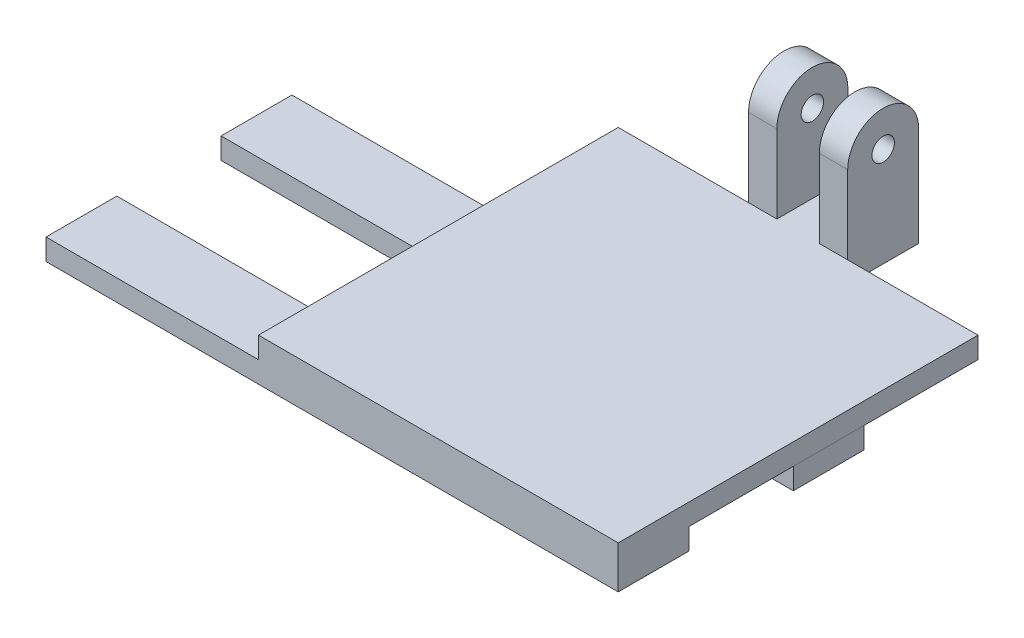
from build123d import *

# Parameters (mm, degrees)
BOSS_EXTRUDE1_DEPTH = 3
SKETCH1_3_W         = 4
SKETCH1_3_H         = 10.023203152
BOSS_EXTRUDE2_DEPTH = 19.05
SKETCH2_R           = 1.5875
CUT_EXTRUDE1_DEPTH  = 19.05
SKETCH3_W           = 80.796379589
SKETCH3_H           = 10
BOSS_EXTRUDE3_DEPTH = 3


with BuildPart() as part:
    # Sketch1 → Boss-Extrude1 (new body)
    with BuildSketch(Plane(origin=(0, 0, 0), x_dir=(1, 0, 0), z_dir=(0, 1, 0))):
        Polygon((0, 50.8), (0, 0), (50.8, 0), (50.8, 50.8), (28.4, 50.8), (28.4, 60.823203152), (22.4, 60.823203152), (22.4, 50.8), align=None)
    extrude(amount=BOSS_EXTRUDE1_DEPTH)

    # Sketch1_3 → Boss-Extrude2 (add)
    with BuildSketch(Plane(origin=(0, 0, 0), x_dir=(1, 0, 0), z_dir=(0, 1, 0))):
        with Locations((20.4, 55.811601576)):
            Rectangle(SKETCH1_3_W, SKETCH1_3_H)
        with Locations((30.4, 55.811601576)):
            Rectangle(SKETCH1_3_W, SKETCH1_3_H)
    extrude(amount=BOSS_EXTRUDE2_DEPTH)

    # Sketch2 → Cut-Extrude1 (cut)
    with BuildSketch(Plane(origin=(32.4, 0, 0), x_dir=(0, 0, -1), z_dir=(1, 0, 0))):
        with Locations((55.811601576, 14.038398424)):
            Circle(SKETCH2_R)
        with BuildLine():
            Line((50.8, 14.038398424), (49.911458456, 20.395059664))
            Line((49.911458456, 20.395059664), (64.501767063, 21.247740037))
            Line((64.501767063, 21.247740037), (60.823203152, 14.038398424))
            ThreePointArc((60.823203152, 14.038398424), (55.811601576, 19.05), (50.8, 14.038398424))
        make_face()
    extrude(amount=-CUT_EXTRUDE1_DEPTH, mode=Mode.SUBTRACT)

    # Sketch3 → Boss-Extrude3 (add)
    with BuildSketch(Plane.XZ):
        Polygon((0, 0), (-30, 0), (-30, -10), (50.8, -10), (50.8, 0), align=None)
        with Locations((10.398189795, -29.723216131)):
            Rectangle(SKETCH3_W, SKETCH3_H)
    extrude(amount=BOSS_EXTRUDE3_DEPTH)


solid = part.part
